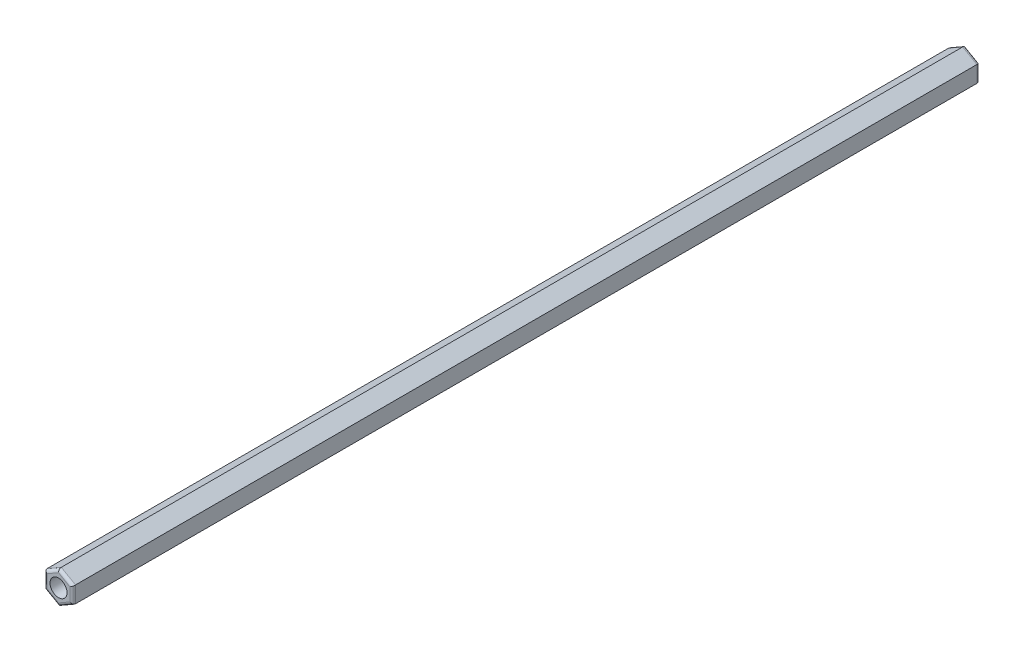
from build123d import *

# Parameters (mm, degrees)
RESSALTO_EXTRUS_O1_DEPTH = 160
FILETE1_R                = 0.5
ESBO_O2_R                = 1.5
CORTE_EXTRUS_O1_DEPTH    = 161


with BuildPart() as part:
    # Esboço1 → Ressalto-extrusão1 (new body)
    with BuildSketch(Plane(origin=(0, 0, 0), x_dir=(-1, 0, 0), z_dir=(0, 0, -1))):
        Polygon((67.502122675, -1.443375673), (70.002122675, -2.886751346), (72.502122675, -1.443375673), (72.502122675, 1.443375673), (70.002122675, 2.886751346), (67.502122675, 1.443375673), align=None)
    extrude(amount=-RESSALTO_EXTRUS_O1_DEPTH)

    # Filete1
    filete1_edges = [part.edges().sort_by_distance(p)[0] for p in [
        (-71.252122675, -2.165063509, 160),
        (-72.502122675, 0, 160),
        (-71.252122675, 2.165063509, 160),
        (-68.752122675, 2.165063509, 160),
        (-67.502122675, 0, 160),
        (-68.752122675, 2.165063509, 0),
        (-71.252122675, 2.165063509, 0),
        (-72.502122675, 0, 0),
        (-71.252122675, -2.165063509, 0),
        (-68.752122675, -2.165063509, 0),
        (-67.502122675, 0, 0),
        (-68.752122675, -2.165063509, 160),
    ]]
    fillet(filete1_edges, radius=FILETE1_R)

    # Esboço2 → Corte-extrusão1 (cut, through all)
    with BuildSketch(Plane.XY.offset(160)):
        with Locations((-70.002122675, 0)):
            Circle(ESBO_O2_R)
    extrude(amount=-CORTE_EXTRUS_O1_DEPTH, mode=Mode.SUBTRACT)


solid = part.part
